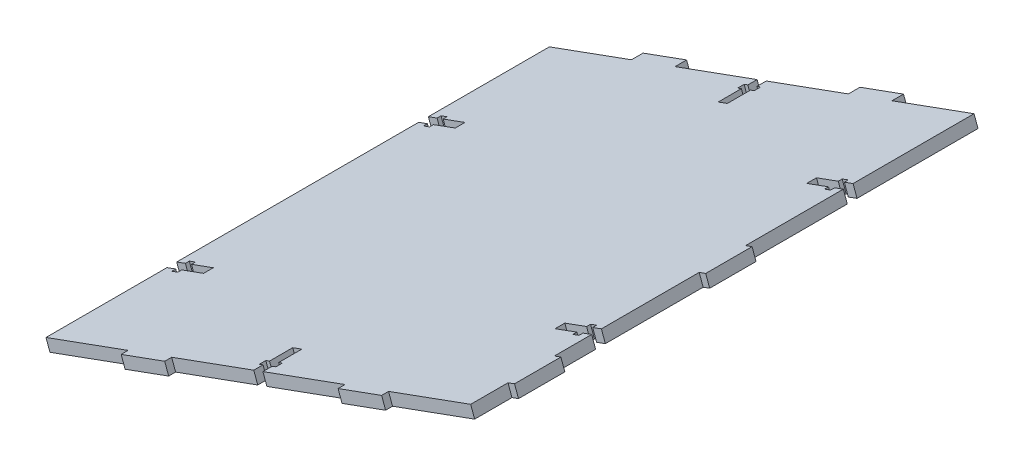
from build123d import *

# Parameters (mm, degrees)
BOSS_EXTRUDE1_DEPTH = 217.2
CUT_EXTRUDE3_DEPTH  = 68.63050203
SKETCH5_W           = 20
SKETCH5_H           = 5
SKETCH5_W_2         = 3
SKETCH5_H_2         = 20
SKETCH5_H_3         = 3
BOSS_EXTRUDE2_DEPTH = 5


with BuildPart() as part:
    # Sketch2 → Boss-Extrude1 (new body)
    with BuildSketch(Plane.XY.offset(2)):
        Polygon((29.309289207, -6.943664177), (31.018091452, -11.642599682), (-152.24039327, -78.285887246), (-153.949195515, -73.586951741), align=None)
    extrude(amount=BOSS_EXTRUDE1_DEPTH)

    # Sketch4 → Cut-Extrude3 (cut, through all)
    with BuildSketch(Plane(origin=(7.362313595, -20.245196221, 0), x_dir=(-0.939787101, -0.341760449, 0), z_dir=(0.341760449, -0.939787101, 0))):
        Polygon((70.228577846, -2), (74.428577846, -2), (74.428577846, -6), (76.128577846, -6), (76.128577846, -8.8), (74.428577846, -8.8), (74.428577846, -18.8), (70.228577846, -18.8), (70.228577846, -8.8), (68.528577846, -8.8), (68.528577846, -6), (70.228577846, -6), align=None)
        Polygon((-25.171422154, -58.4), (-25.171422154, -54.2), (-21.171422154, -54.2), (-21.171422154, -52.5), (-18.371422154, -52.5), (-18.371422154, -54.2), (-8.371422154, -54.2), (-8.371422154, -58.4), (-18.371422154, -58.4), (-18.371422154, -60.1), (-21.171422154, -60.1), (-21.171422154, -58.4), align=None)
        Polygon((74.428577846, -219.2), (70.228577846, -219.2), (70.228577846, -215.2), (68.528577846, -215.2), (68.528577846, -212.4), (70.228577846, -212.4), (70.228577846, -202.4), (74.428577846, -202.4), (74.428577846, -212.4), (76.128577846, -212.4), (76.128577846, -215.2), (74.428577846, -215.2), align=None)
        Polygon((-21.171422154, -167), (-21.171422154, -168.7), (-18.371422154, -168.7), (-18.371422154, -167), (-8.371422154, -167), (-8.371422154, -162.8), (-18.371422154, -162.8), (-18.371422154, -161.1), (-21.171422154, -161.1), (-21.171422154, -162.8), (-25.171422154, -162.8), (-25.171422154, -167), align=None)
        Polygon((169.828577846, -162.8), (169.828577846, -167), (165.828577846, -167), (165.828577846, -168.7), (163.028577846, -168.7), (163.028577846, -167), (153.028577846, -167), (153.028577846, -162.8), (163.028577846, -162.8), (163.028577846, -161.1), (165.828577846, -161.1), (165.828577846, -162.8), align=None)
        Polygon((165.828577846, -54.2), (165.828577846, -52.5), (163.028577846, -52.5), (163.028577846, -54.2), (153.028577846, -54.2), (153.028577846, -58.4), (163.028577846, -58.4), (163.028577846, -60.1), (165.828577846, -60.1), (165.828577846, -58.4), (169.828577846, -58.4), (169.828577846, -54.2), align=None)
    extrude(amount=-CUT_EXTRUDE3_DEPTH, mode=Mode.SUBTRACT)

    # Sketch5 → Boss-Extrude2 (add)
    with BuildSketch(Plane(origin=(7.362313595, -20.245196221, 0), x_dir=(0.939787101, 0.341760449, 0), z_dir=(0.341760449, -0.939787101, 0))):
        with Locations((-22.528577846, -0.5)):
            Rectangle(SKETCH5_W, SKETCH5_H)
        with Locations((-122.128577846, -0.5)):
            Rectangle(SKETCH5_W, SKETCH5_H)
        with Locations((26.671422154, 110.6)):
            Rectangle(SKETCH5_W_2, SKETCH5_H_2)
        with Locations((26.671422154, 193.1)):
            Rectangle(SKETCH5_W_2, SKETCH5_H_2)
        with Locations((-22.528577846, 220.7)):
            Rectangle(SKETCH5_W, SKETCH5_H_3)
        with Locations((-122.128577846, 220.7)):
            Rectangle(SKETCH5_W, SKETCH5_H_3)
    extrude(amount=-BOSS_EXTRUDE2_DEPTH)


solid = part.part
